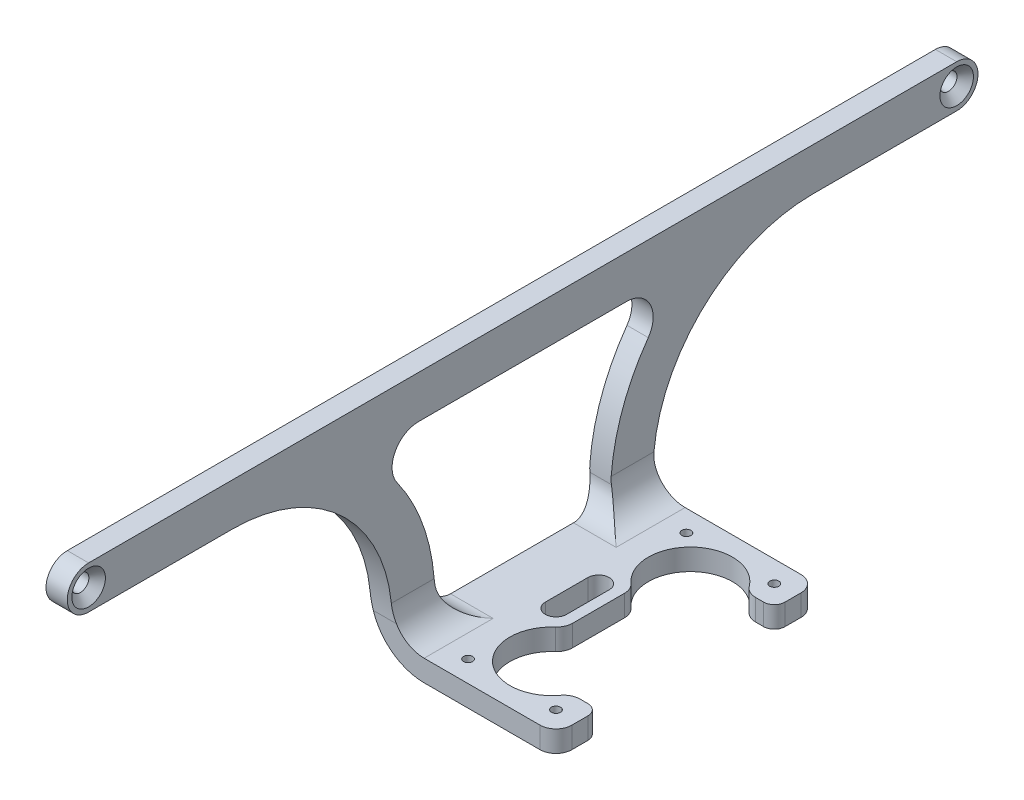
from build123d import *

# Parameters (mm, degrees)
BOSS_EXTRU_1_DEPTH                             = 171
FRAISAGE_POUR_VIS_T_TE_FRAIS_E_M31_D           = 3.2
FRAISAGE_POUR_VIS_T_TE_FRAIS_E_M31_DEPTH       = 4
FRAISAGE_POUR_VIS_T_TE_FRAIS_E_M31_CSINK_D     = 6.3
FRAISAGE_POUR_VIS_T_TE_FRAIS_E_M31_CSINK_ANGLE = 90
D_GAGEMENT_M1_61_D                             = 1.7
D_GAGEMENT_M1_61_DEPTH                         = 4
ENL_V_MAT_EXTRU_1_DEPTH                        = 4
ENL_V_MAT_EXTRU_2_DEPTH                        = 31.75
ENL_V_MAT_EXTRU_2_DEPTH_BACK                   = 5


with BuildPart() as part:
    # Esquisse1 → Boss.-Extru.1 (new body)
    with BuildSketch(Plane.XY):
        with BuildLine():
            Line((0, 0), (-25, 0))
            ThreePointArc((-25, 0), (-32.071067812, 2.928932188), (-35, 10))
            Line((-35, 10), (-35, 45))
            Line((-35, 45), (-31, 45))
            Line((-31, 45), (-31, 10))
            ThreePointArc((-31, 10), (-29.242640687, 5.757359313), (-25, 4))
            Line((-25, 4), (0, 4))
            Line((0, 4), (0, 0))
        make_face()
    extrude(amount=BOSS_EXTRU_1_DEPTH)

    # Fraisage pour vis à tête fraisée M31
    with Locations(Plane(origin=(-31, 0, 0), x_dir=(0, 0, 1), z_dir=(1, 0, 0))):
        with Locations((4, -41), (167, -41)):
            CounterSinkHole(FRAISAGE_POUR_VIS_T_TE_FRAIS_E_M31_D / 2, FRAISAGE_POUR_VIS_T_TE_FRAIS_E_M31_CSINK_D / 2, depth=FRAISAGE_POUR_VIS_T_TE_FRAIS_E_M31_DEPTH, counter_sink_angle=FRAISAGE_POUR_VIS_T_TE_FRAIS_E_M31_CSINK_ANGLE)

    # Dégagement M1.61
    with Locations(Plane(origin=(0, 0, 0), x_dir=(-1, 0, 0), z_dir=(0, -1, 0))):
        with Locations((20.75, -65), (20.75, -106), (4.25, -106), (4.25, -65)):
            Hole(D_GAGEMENT_M1_61_D / 2, depth=D_GAGEMENT_M1_61_DEPTH)

    # Esquisse6 → Enlèv. mat.-Extru.1 (cut)
    with BuildSketch(Plane.XZ):
        with BuildLine():
            Line((-35, 61), (-3.25, 61))
            ThreePointArc((-3.25, 61), (-1.128679656, 61.878679656), (-0.25, 64))
            Line((-0.25, 64), (-0.25, 67))
            ThreePointArc((-0.25, 67), (-0.835786438, 68.414213562), (-2.25, 69))
            Line((-2.25, 69), (-3.750142858, 69))
            ThreePointArc((-3.750142858, 69), (-5.097923909, 68.680202649), (-6.15836042, 67.788990826))
            ThreePointArc((-6.15836042, 67.788990826), (-17.832822404, 66.671534919), (-17.754587156, 78.399094322))
            ThreePointArc((-17.754587156, 78.399094322), (-17.012643745, 79.411706018), (-16.75, 80.639256723))
            Line((-16.75, 80.639256723), (-16.75, 90.360743277))
            ThreePointArc((-16.75, 90.360743277), (-17.012643745, 91.588293982), (-17.754587156, 92.600905678))
            ThreePointArc((-17.754587156, 92.600905678), (-17.832822404, 104.328465081), (-6.15836042, 103.211009174))
            ThreePointArc((-6.15836042, 103.211009174), (-5.097923909, 102.319797351), (-3.750142858, 102))
            Line((-3.750142858, 102), (-2.25, 102))
            ThreePointArc((-2.25, 102), (-0.835786438, 102.585786438), (-0.25, 104))
            Line((-0.25, 104), (-0.25, 107))
            ThreePointArc((-0.25, 107), (-1.128679656, 109.121320344), (-3.25, 110))
            Line((-3.25, 110), (-35, 110))
            Line((-35, 110), (-35, 171))
            Line((-35, 171), (0, 171))
            Line((0, 171), (0, 0))
            Line((0, 0), (-35, 0))
            Line((-35, 0), (-35, 61))
        make_face()
        with BuildLine():
            Line((-18.75, 89.5), (-18.75, 81.5))
            ThreePointArc((-18.75, 81.5), (-20.75, 79.5), (-22.75, 81.5))
            Line((-22.75, 81.5), (-22.75, 89.5))
            ThreePointArc((-22.75, 89.5), (-20.75, 91.5), (-18.75, 89.5))
        make_face()
    extrude(amount=-ENL_V_MAT_EXTRU_1_DEPTH, mode=Mode.SUBTRACT)

    # Esquisse7 → Enlèv. mat.-Extru.2 (cut, two sides)
    with BuildSketch(Plane(origin=(-31, 0, 0), x_dir=(0, 0, -1), z_dir=(1, 0, 0))) as enl_v_mat_extru_2_sk:
        with BuildLine():
            ThreePointArc((-4, 45), (-1.171572875, 43.828427125), (0, 41))
            Line((0, 41), (0, 45))
            Line((0, 45), (-4, 45))
        make_face()
        with BuildLine():
            Line((0, 4), (0, 41))
            ThreePointArc((0, 41), (-1.171572875, 38.171572875), (-4, 37))
            Line((-4, 37), (-31, 37))
            ThreePointArc((-31, 37), (-52.213203436, 28.213203436), (-61, 7))
            Line((-61, 7), (-61, 4))
            Line((-61, 4), (0, 4))
        make_face()
        with BuildLine():
            ThreePointArc((-167, 37), (-169.828427125, 38.171572875), (-171, 41))
            Line((-171, 41), (-171, 4))
            Line((-171, 4), (-110, 4))
            Line((-110, 4), (-110, 7))
            ThreePointArc((-110, 7), (-118.786796564, 28.213203436), (-140, 37))
            Line((-140, 37), (-167, 37))
        make_face()
        with BuildLine():
            Line((-171, 45), (-171, 41))
            ThreePointArc((-171, 41), (-169.828427125, 43.828427125), (-167, 45))
            Line((-167, 45), (-171, 45))
        make_face()
        with BuildLine():
            Line((-65.985711369, 37), (-105.014288631, 37))
            ThreePointArc((-105.014288631, 37), (-109.460347769, 34.287478555), (-109.082394604, 29.093023256))
            ThreePointArc((-109.082394604, 29.093023256), (-104.093528666, 19.438863146), (-102.041125553, 8.76744186))
            ThreePointArc((-102.041125553, 8.76744186), (-100.498870029, 5.383178834), (-97.04653681, 4))
            Line((-97.04653681, 4), (-73.95346319, 4))
            ThreePointArc((-73.95346319, 4), (-70.501129971, 5.383178834), (-68.958874447, 8.76744186))
            ThreePointArc((-68.958874447, 8.76744186), (-66.906471334, 19.438863146), (-61.917605396, 29.093023256))
            ThreePointArc((-61.917605396, 29.093023256), (-61.539652231, 34.287478555), (-65.985711369, 37))
        make_face()
    extrude(amount=ENL_V_MAT_EXTRU_2_DEPTH, mode=Mode.SUBTRACT)
    extrude(enl_v_mat_extru_2_sk.sketch, amount=-ENL_V_MAT_EXTRU_2_DEPTH_BACK, mode=Mode.SUBTRACT)


solid = part.part
